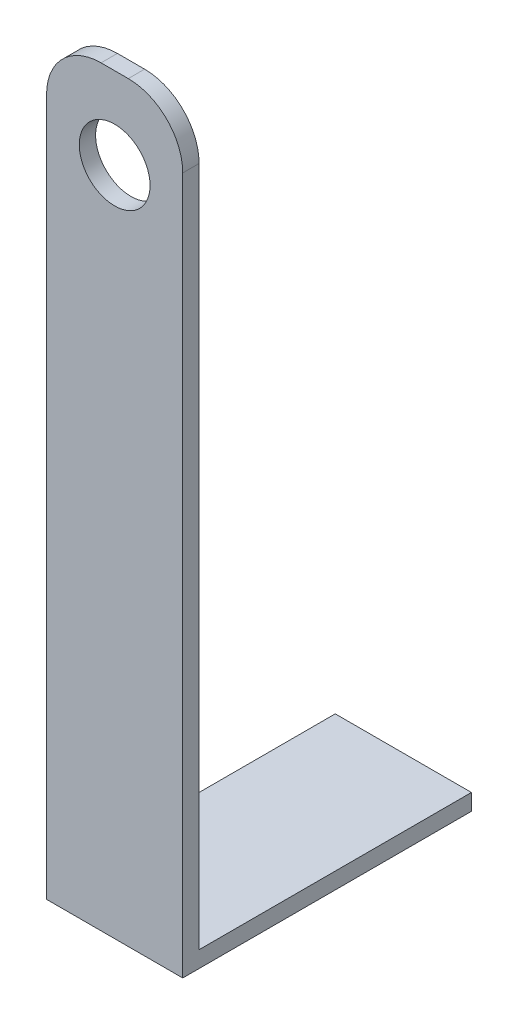
from build123d import *

# Parameters (mm, degrees)
CROQUIS1_W              = 50
CROQUIS1_H              = 100
SALIENTE_EXTRUIR1_DEPTH = 6
CROQUIS2_W              = 50
CROQUIS2_H              = 6
SALIENTE_EXTRUIR2_DEPTH = 276
CROQUIS3_R              = 13
CORTAR_EXTRUIR1_DEPTH   = 6
REDONDEO1_R             = 20


with BuildPart() as part:
    # Croquis1 → Saliente-Extruir1 (new body)
    with BuildSketch(Plane(origin=(0, 0, 0), x_dir=(1, 0, 0), z_dir=(0, 1, 0))):
        Rectangle(CROQUIS1_W, CROQUIS1_H)
    extrude(amount=SALIENTE_EXTRUIR1_DEPTH)

    # Croquis2 → Saliente-Extruir2 (add)
    with BuildSketch(Plane.XZ):
        with Locations((0, 53)):
            Rectangle(CROQUIS2_W, CROQUIS2_H)
    extrude(amount=-SALIENTE_EXTRUIR2_DEPTH)

    # Croquis3 → Cortar-Extruir1 (cut)
    with BuildSketch(Plane.XY.offset(56)):
        with Locations((0, 246)):
            Circle(CROQUIS3_R)
    extrude(amount=-CORTAR_EXTRUIR1_DEPTH, mode=Mode.SUBTRACT)

    # Redondeo1
    redondeo1_edges = [part.edges().sort_by_distance(p)[0] for p in [
        (25, 276, 53),
        (-25, 276, 53),
    ]]
    fillet(redondeo1_edges, radius=REDONDEO1_R)


solid = part.part
